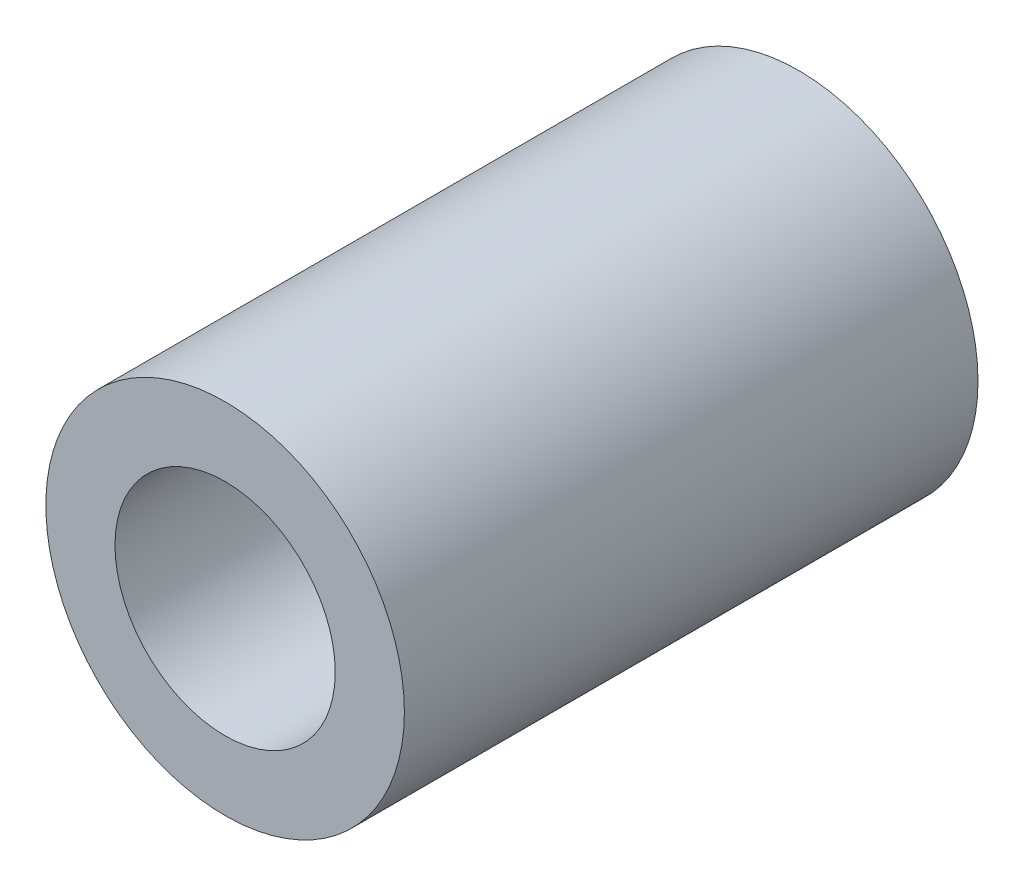
from build123d import *

# Parameters (mm, degrees)
SKETCH1_R           = 3.96875
SKETCH1_R_2         = 2.4384
EXTRUDE1_DEPTH      = 6.35
EXTRUDE1_DEPTH_BACK = 6.35


with BuildPart() as part:
    # Sketch1 → Extrude1 (new body, two sides)
    with BuildSketch(Plane.XY) as extrude1_sk:
        Circle(SKETCH1_R)
        Circle(SKETCH1_R_2, mode=Mode.SUBTRACT)
    extrude(amount=EXTRUDE1_DEPTH)
    extrude(extrude1_sk.sketch, amount=-EXTRUDE1_DEPTH_BACK)


solid = part.part
